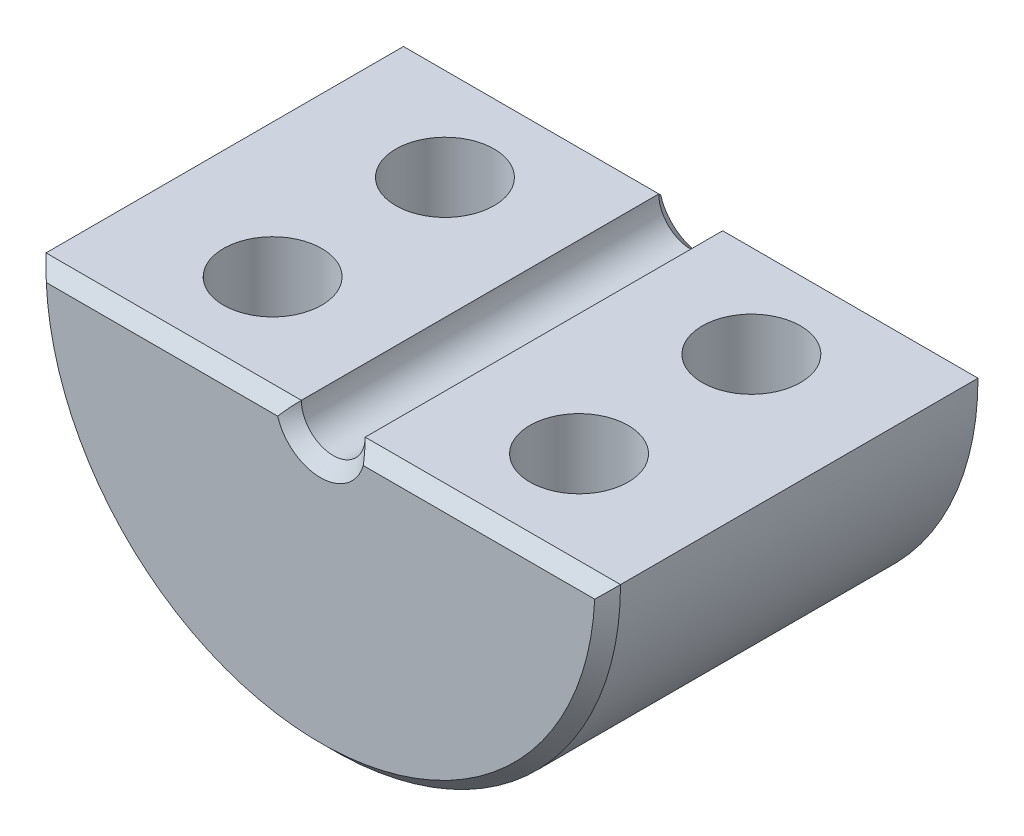
from build123d import *

# Parameters (mm, degrees)
BOSS_EXTRUDE2_DEPTH = 15.24
CHAMFER1_SIZE       = 0.508
CHAMFER2_SIZE       = 0.508
SKETCH13_R          = 1.9558
CUT_EXTRUDE1_DEPTH  = 7.62


with BuildPart() as part:
    # Sketch9 → Boss-Extrude2 (new body)
    with BuildSketch(Plane.XY):
        with BuildLine():
            Line((-11.43, 0), (-1.27, 0))
            ThreePointArc((-1.27, 0), (0, -1.27), (1.27, 0))
            Line((1.27, 0), (11.43, 0))
            ThreePointArc((11.43, 0), (0, -11.43), (-11.43, 0))
        make_face()
    extrude(amount=BOSS_EXTRUDE2_DEPTH)

    # Chamfer1
    chamfer1_edges = [part.edges().sort_by_distance(p)[0] for p in [
        (6.35, 0, 0),
        (0, -11.43, 0),
        (-6.35, 0, 0),
        (0, -1.27, 0),
    ]]
    chamfer(chamfer1_edges, length=CHAMFER1_SIZE)

    # Chamfer2
    chamfer2_edges = [part.edges().sort_by_distance(p)[0] for p in [
        (0, -11.43, 15.24),
        (6.35, 0, 15.24),
        (0, -1.27, 15.24),
        (-6.35, 0, 15.24),
    ]]
    chamfer(chamfer2_edges, length=CHAMFER2_SIZE)

    # Sketch13 → Cut-Extrude1 (cut)
    with BuildSketch(Plane(origin=(0, 0, 0), x_dir=(1, 0, 0), z_dir=(0, 1, 0))):
        with Locations((-6.096, -4.191)):
            Circle(SKETCH13_R)
        with Locations((-6.096, -11.049)):
            Circle(SKETCH13_R)
        with Locations((6.096, -11.049)):
            Circle(SKETCH13_R)
        with Locations((6.096, -4.191)):
            Circle(SKETCH13_R)
    extrude(amount=-CUT_EXTRUDE1_DEPTH, mode=Mode.SUBTRACT)


solid = part.part
